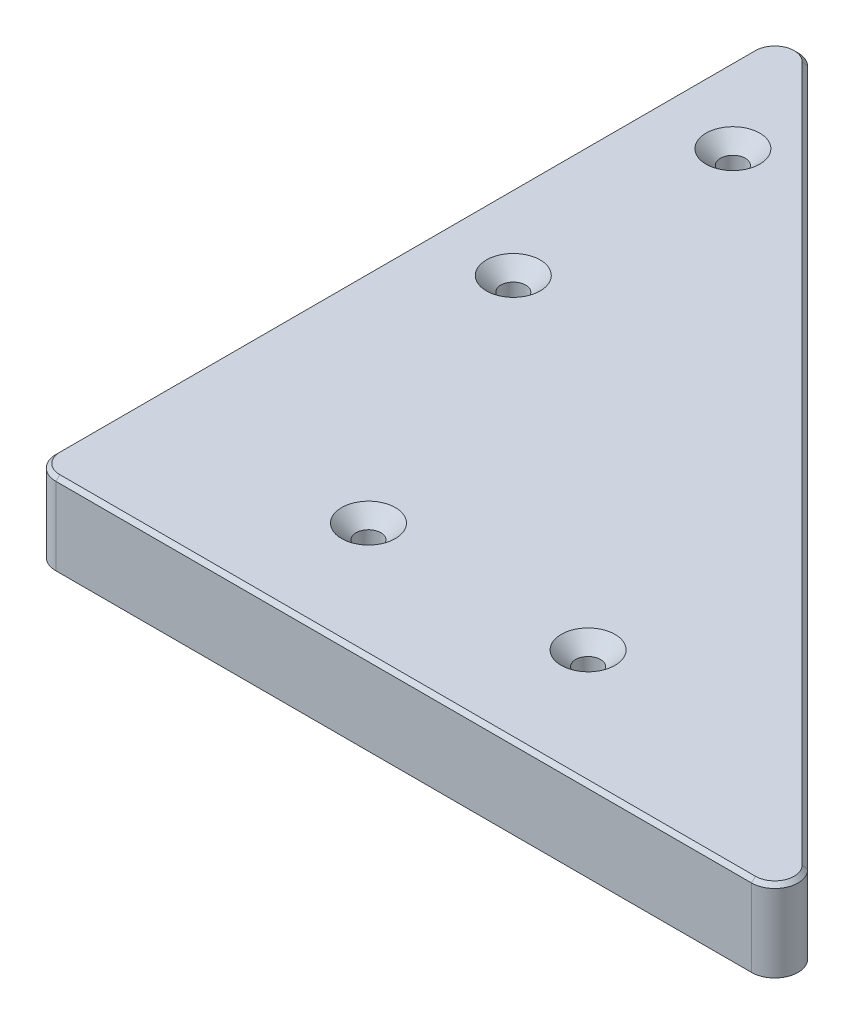
from build123d import *

# Parameters (mm, degrees)
SKETCH1_R                                            = 1
MAIN_BODY_DEPTH                                      = 10.5
PROFILE_STOPS_DEPTH                                  = 20
CSK_FOR_M3_HEX_SOCKET_COUNTERSUNK_HEAD_S_D           = 3.2
CSK_FOR_M3_HEX_SOCKET_COUNTERSUNK_HEAD_S_DEPTH       = 30.5
CSK_FOR_M3_HEX_SOCKET_COUNTERSUNK_HEAD_S_CSINK_D     = 6.94
CSK_FOR_M3_HEX_SOCKET_COUNTERSUNK_HEAD_S_CSINK_ANGLE = 90
FILLET1_R                                            = 3
FILLET3_R                                            = 2
CHAMFER1_SIZE                                        = 0.5


with BuildPart() as part:
    # Sketch1 → Main Body (new body)
    with BuildSketch(Plane(origin=(0, 0, 0), x_dir=(1, 0, 0), z_dir=(0, 1, 0))):
        Polygon((-48, -6.5), (52, -6.5), (-48, 93.5), align=None)
        with Locations((-19.666666667, 8.5)):
            Circle(SKETCH1_R, mode=Mode.SUBTRACT)
        with Locations((8.666666667, 8.5)):
            Circle(SKETCH1_R, mode=Mode.SUBTRACT)
        with Locations((-38, 45.516187598)):
            Circle(SKETCH1_R, mode=Mode.SUBTRACT)
        with Locations((-38, 73.849520931)):
            Circle(SKETCH1_R, mode=Mode.SUBTRACT)
    extrude(amount=MAIN_BODY_DEPTH)

    # Sketch1_3 → Profile Stops (add)
    with BuildSketch(Plane(origin=(0, 0, 0), x_dir=(1, 0, 0), z_dir=(0, 1, 0))):
        Polygon((-48, 23.5), (-48, 18.5), (27, 18.5), (-28, 73.5), (-28, 23.5), (-41, 23.5), align=None)
    extrude(amount=-PROFILE_STOPS_DEPTH)

    # CSK for M3 Hex Socket Countersunk Head S
    with Locations(Plane(origin=(-38, 10.5, -73.849520931), x_dir=(0, 0, 1), z_dir=(0, 1, 0))):
        with Locations((0, 0), (28.333333333, 0), (65.349520931, 46.666666667), (65.349520931, 18.333333333)):
            CounterSinkHole(CSK_FOR_M3_HEX_SOCKET_COUNTERSUNK_HEAD_S_D / 2, CSK_FOR_M3_HEX_SOCKET_COUNTERSUNK_HEAD_S_CSINK_D / 2, depth=CSK_FOR_M3_HEX_SOCKET_COUNTERSUNK_HEAD_S_DEPTH, counter_sink_angle=CSK_FOR_M3_HEX_SOCKET_COUNTERSUNK_HEAD_S_CSINK_ANGLE)

    # Fillet1
    fillet1_edges = [part.edges().sort_by_distance(p)[0] for p in [
        (-48, 5.25, 6.5),
        (52, 5.25, 6.5),
        (-28, -10, -73.5),
        (27, -10, -18.5),
        (-48, 5.25, -93.5),
    ]]
    fillet(fillet1_edges, radius=FILLET1_R)

    # Fillet3
    fillet3_edges = [part.edges().sort_by_distance(p)[0] for p in [
        (-48, -10, -23.5),
        (-48, -10, -18.5),
    ]]
    fillet(fillet3_edges, radius=FILLET3_R)

    # Chamfer1
    chamfer1_edges = [part.edges().sort_by_distance(p)[0] for p in [
        (-48, 10.5, -41.378679656),
        (2, 10.5, -43.5),
        (-47.121320344, 10.5, 5.621320344),
        (47.52899791, 10.5, 4.648050297),
        (-0.121320344, 10.5, 6.5),
        (-46.148050297, 10.5, -89.02899791),
    ]]
    chamfer(chamfer1_edges, length=CHAMFER1_SIZE)


solid = part.part
